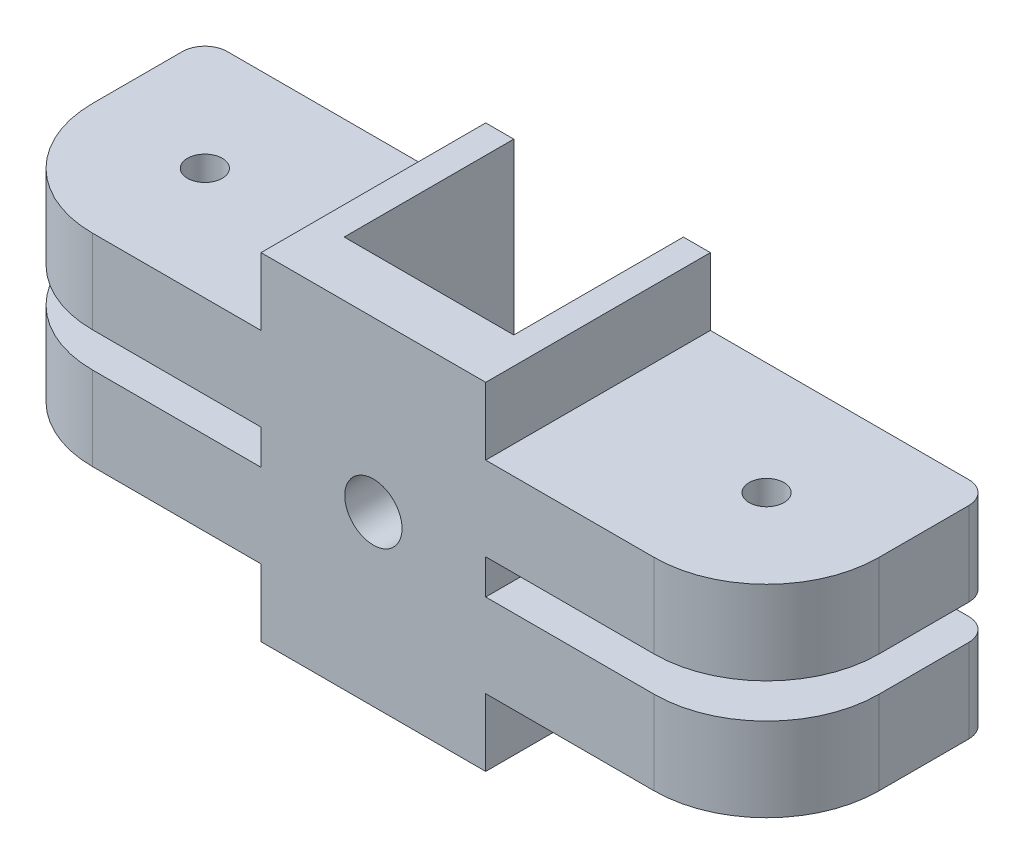
from build123d import *

# Parameters (mm, degrees)
SKETCH_1_R          = 2.55
EXTRUDE_1_DEPTH     = 20
CUT_EXTRUDE_1_REACH = 32
SKETCH_2_W          = 15.1
SKETCH_2_H          = 15.1
SKETCH_3_R          = 1.55
CUT_EXTRUDE_2_DEPTH = 100
FILLET_1_R          = 2
FILLET_2_R          = 10


with BuildPart() as part:
    # 草图1 → 凸台-拉伸1 (new body)
    with BuildSketch(Plane.XY):
        Polygon((10, 9), (10, 15), (-10, 15), (-10, 9), (-35, 9), (-35, 1.55), (-10, 1.55), (-10, -1.55), (-35, -1.55), (-35, -9), (-10, -9), (-10, -15), (10, -15), (10, -9), (35, -9), (35, -1.55), (10, -1.55), (10, 1.55), (35, 1.55), (35, 9), align=None)
        Circle(SKETCH_1_R, mode=Mode.SUBTRACT)
    extrude(amount=EXTRUDE_1_DEPTH)

    # 草图2 → 切除-拉伸1 (cut, up to next)
    with BuildSketch(Plane.XZ.offset(15), mode=Mode.PRIVATE) as cut_extrude_1_sk1:
        with Locations((0.05, 7.55)):
            Rectangle(SKETCH_2_W, SKETCH_2_H)
    cut_extrude_1_tool1 = extrude(cut_extrude_1_sk1.sketch, amount=-CUT_EXTRUDE_1_REACH, mode=Mode.PRIVATE) & part.part
    add(cut_extrude_1_tool1.solids().sort_by_distance((0.05, -15, 7.55))[0], mode=Mode.SUBTRACT)

    # 草图3 → 切除-拉伸2 (cut)
    with BuildSketch(Plane(origin=(0, 9, 0), x_dir=(1, 0, 0), z_dir=(0, 1, 0))):
        with Locations((25, -10)):
            Circle(SKETCH_3_R)
    cut_extrude_2 = extrude(amount=-CUT_EXTRUDE_2_DEPTH, mode=Mode.SUBTRACT)

    # 镜向1: 切除-拉伸2 across plane
    add(cut_extrude_2.mirror(Plane(origin=(0, 0, 0), x_dir=(0, 0, 1), z_dir=(1, 0, 0))), mode=Mode.SUBTRACT)

    # 圆角1
    fillet_1_edges = [part.edges().sort_by_distance(p)[0] for p in [
        (-35, -5.275, 0),
        (-35, 5.275, 0),
        (35, 5.275, 0),
        (35, -5.275, 0),
    ]]
    fillet(fillet_1_edges, radius=FILLET_1_R)

    # 圆角2
    fillet_2_edges = [part.edges().sort_by_distance(p)[0] for p in [
        (35, -5.275, 20),
        (35, 5.275, 20),
        (-35, 5.275, 20),
        (-35, -5.275, 20),
    ]]
    fillet(fillet_2_edges, radius=FILLET_2_R)


solid = part.part
